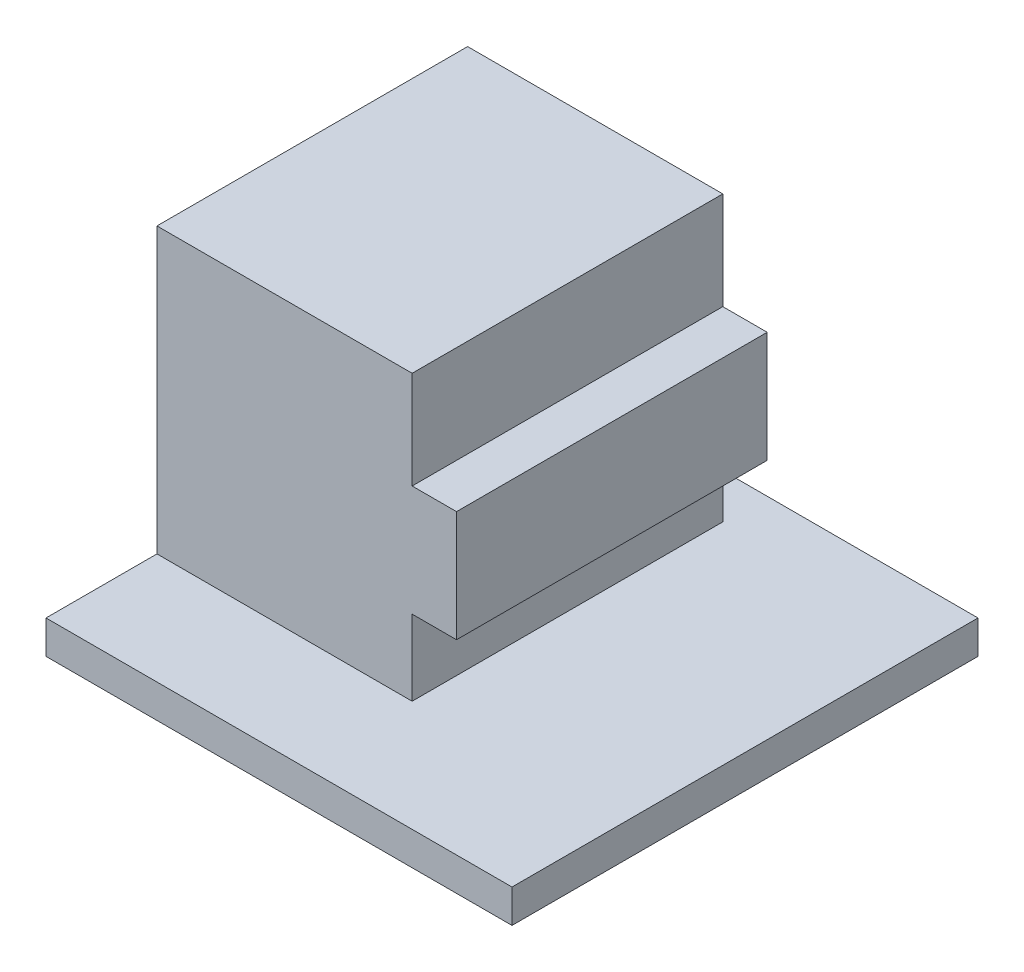
from build123d import *

# Parameters (mm, degrees)
SKETCH1_W           = 21
SKETCH1_H           = 21
BOSS_EXTRUDE1_DEPTH = 1.5
BOSS_EXTRUDE3_DEPTH = 14


with BuildPart() as part:
    # Sketch1 → Boss-Extrude1 (new body)
    with BuildSketch(Plane(origin=(0, 0, 0), x_dir=(1, 0, 0), z_dir=(0, 1, 0))):
        with Locations((10.5, 10.5)):
            Rectangle(SKETCH1_W, SKETCH1_H)
    extrude(amount=BOSS_EXTRUDE1_DEPTH)

    # Sketch3 → Boss-Extrude3 (add)
    with BuildSketch(Plane(origin=(0, 0, -19), x_dir=(-1, 0, 0), z_dir=(0, 0, -1))):
        Polygon((0, 1.5), (0, 14.3), (-11.5, 14.3), (-11.5, 9.9), (-13.5, 9.9), (-13.5, 4.9), (-11.5, 4.9), (-11.5, 1.5), align=None)
    extrude(amount=-BOSS_EXTRUDE3_DEPTH)


solid = part.part
